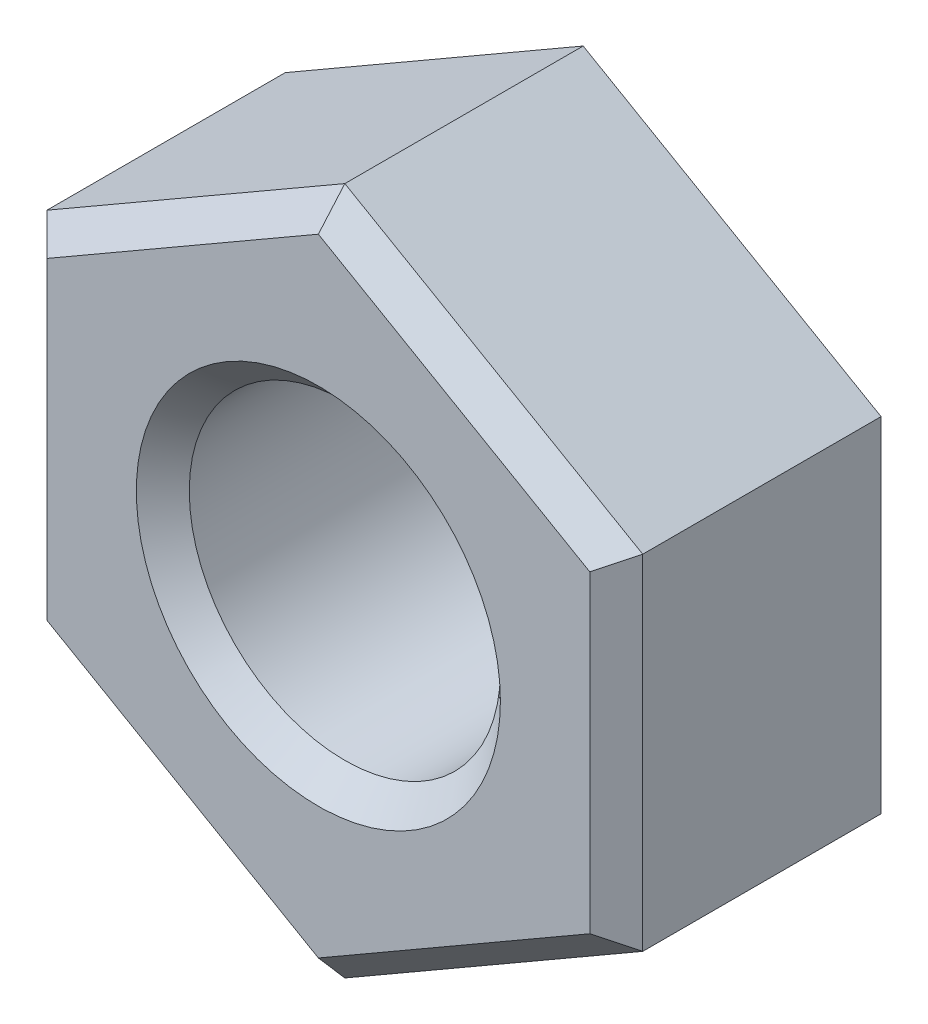
from build123d import *

# Parameters (mm, degrees)
SKETCH1_R           = 2.35
BOSS_EXTRUDE1_DEPTH = 4
CHAMFER1_SIZE       = 0.4


with BuildPart() as part:
    # Sketch1 → Boss-Extrude1 (new body)
    with BuildSketch(Plane.XY):
        Polygon((4.5, -2.598076211), (4.5, 2.598076211), (0, 5.196152423), (-4.5, 2.598076211), (-4.5, -2.598076211), (0, -5.196152423), align=None)
        Circle(SKETCH1_R, mode=Mode.SUBTRACT)
    extrude(amount=BOSS_EXTRUDE1_DEPTH)

    # Chamfer1
    chamfer1_edges = [part.edges().sort_by_distance(p)[0] for p in [
        (2.25, 3.897114317, 4),
        (-2.25, 3.897114317, 4),
        (-2.35, 0, 4),
        (-4.5, 0, 4),
        (-2.25, -3.897114317, 4),
        (2.25, -3.897114317, 4),
        (4.5, 0, 4),
    ]]
    chamfer(chamfer1_edges, length=CHAMFER1_SIZE)


solid = part.part
